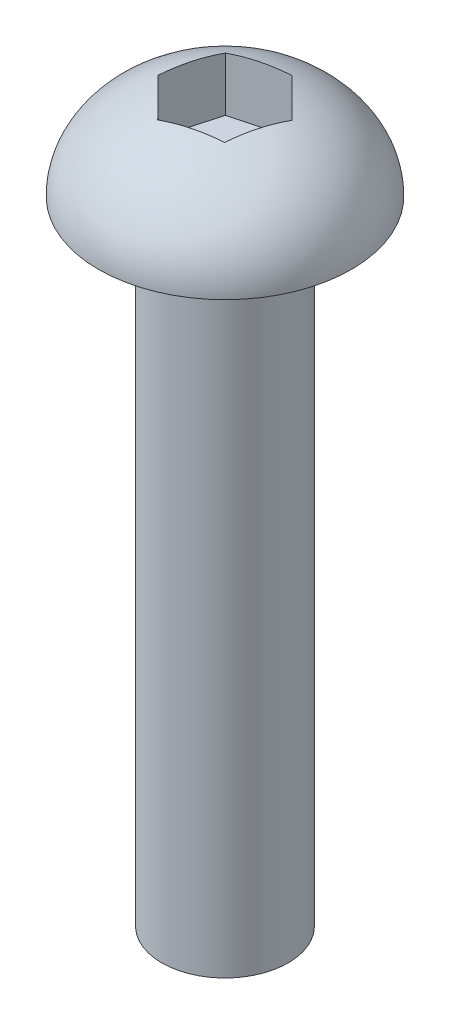
from build123d import *

# Parameters (mm, degrees)
SKETCH_1_R          = 1
EXTRUDE_1_DEPTH     = 10
SKETCH_2_R          = 2
EXTRUDE_2_DEPTH     = 1.5
CUT_EXTRUDE_1_DEPTH = 1


with BuildPart() as part:
    # 草图1 → 凸台-拉伸1 (new body)
    with BuildSketch(Plane(origin=(0, 0, 0), x_dir=(1, 0, 0), z_dir=(0, 1, 0))):
        Circle(SKETCH_1_R)
    extrude(amount=EXTRUDE_1_DEPTH)

    # 草图2 → 凸台-拉伸2 (add)
    with BuildSketch(Plane(origin=(0, 10, 0), x_dir=(1, 0, 0), z_dir=(0, 1, 0))):
        Circle(SKETCH_2_R)
    extrude(amount=EXTRUDE_2_DEPTH)

    # 草图3 → 切除-拉伸1 (cut)
    with BuildSketch(Plane(origin=(0, 11.5, 0), x_dir=(1, 0, 0), z_dir=(0, 1, 0))):
        Polygon((0.609304592, -0.615424987), (0.837625969, 0.219960762), (0.228321377, 0.835385749), (-0.609304592, 0.615424987), (-0.837625969, -0.219960762), (-0.228321377, -0.835385749), align=None)
    extrude(amount=-CUT_EXTRUDE_1_DEPTH, mode=Mode.SUBTRACT)

    # 草图5 → 切除-旋转4 (revolve, cut)
    with BuildSketch(Plane.XY):
        with BuildLine():
            add(Edge.make_bspline(
                [(-0.5, 11.452368755), (-2, 11.161895004), (-2, 10)],
                knots=[4.965069236, 4.965069236, 4.965069236, 6.283185307, 6.283185307, 6.283185307], degree=2, weights=[1, 0.790569415, 1]))
            Line((-2, 10), (-2, 11.5))
            Line((-2, 11.5), (-0.5, 11.5))
            Line((-0.5, 11.5), (-0.5, 11.452368755))
        make_face()
    revolve(axis=Axis((0, 11.5, 0), (0, -1, 0)), mode=Mode.SUBTRACT)


solid = part.part
